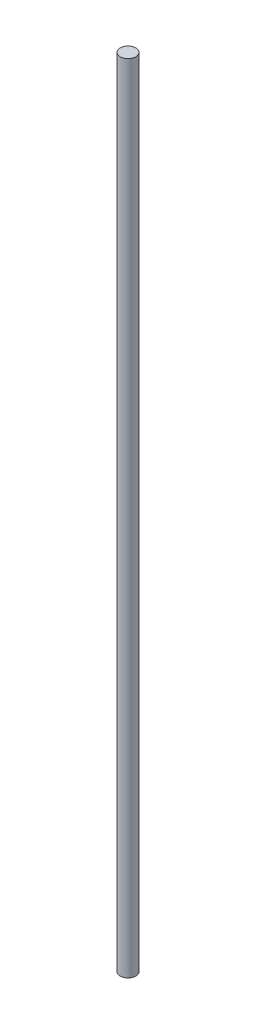
from build123d import *

# Parameters (mm, degrees)
SKETCH1_R           = 0.875
BOSS_EXTRUDE1_DEPTH = 90


with BuildPart() as part:
    # Sketch1 → Boss-Extrude1 (new body)
    with BuildSketch(Plane(origin=(0, 0, 0), x_dir=(1, 0, 0), z_dir=(0, 1, 0))):
        Circle(SKETCH1_R)
    extrude(amount=BOSS_EXTRUDE1_DEPTH)


solid = part.part
